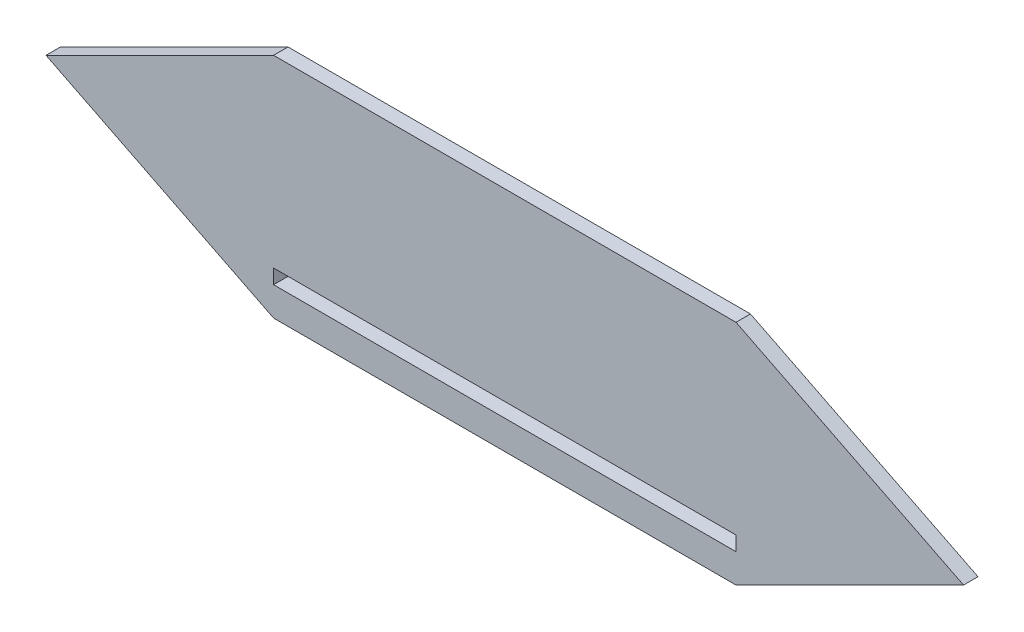
from build123d import *

# Parameters (mm, degrees)
BOSS_EXTRUDE1_DEPTH = 6.35
BOSS_EXTRUDE3_DEPTH = 25
SKETCH3_W           = 203.2
SKETCH3_H           = 6.35
CUT_EXTRUDE1_DEPTH  = 10


with BuildPart() as part:
    # Sketch1 → Boss-Extrude1 (new body)
    with BuildSketch(Plane.XY):
        Polygon((0, 0), (203.2, 0), (303.2, 50), (203.2, 100), (0, 100), (-100, 50), align=None)
    extrude(amount=BOSS_EXTRUDE1_DEPTH)

    # Sketch2 → Boss-Extrude3 (add)
    with BuildSketch(Plane(origin=(0, 0, 0), x_dir=(-1, 0, 0), z_dir=(0, 0, -1))):
        Polygon((-177.8, 12.7), (-203.2, 12.7), (-203.2, 19.05), (-177.8, 19.05), (-177.8, 25.05), (-209.2, 25.05), (-209.2, 6.7), (-177.8, 6.7), align=None)
        Polygon((6, 6.7), (6, 25.05), (-25.4, 25.05), (-25.4, 19.05), (0, 19.05), (0, 12.7), (-25.4, 12.7), (-25.4, 6.7), align=None)
    extrude(amount=BOSS_EXTRUDE3_DEPTH)

    # Sketch3 → Cut-Extrude1 (cut)
    with BuildSketch(Plane(origin=(0, 0, 0), x_dir=(-1, 0, 0), z_dir=(0, 0, -1))):
        with Locations((-101.6, 15.875)):
            Rectangle(SKETCH3_W, SKETCH3_H)
    extrude(amount=-CUT_EXTRUDE1_DEPTH, mode=Mode.SUBTRACT)


solid = part.part
